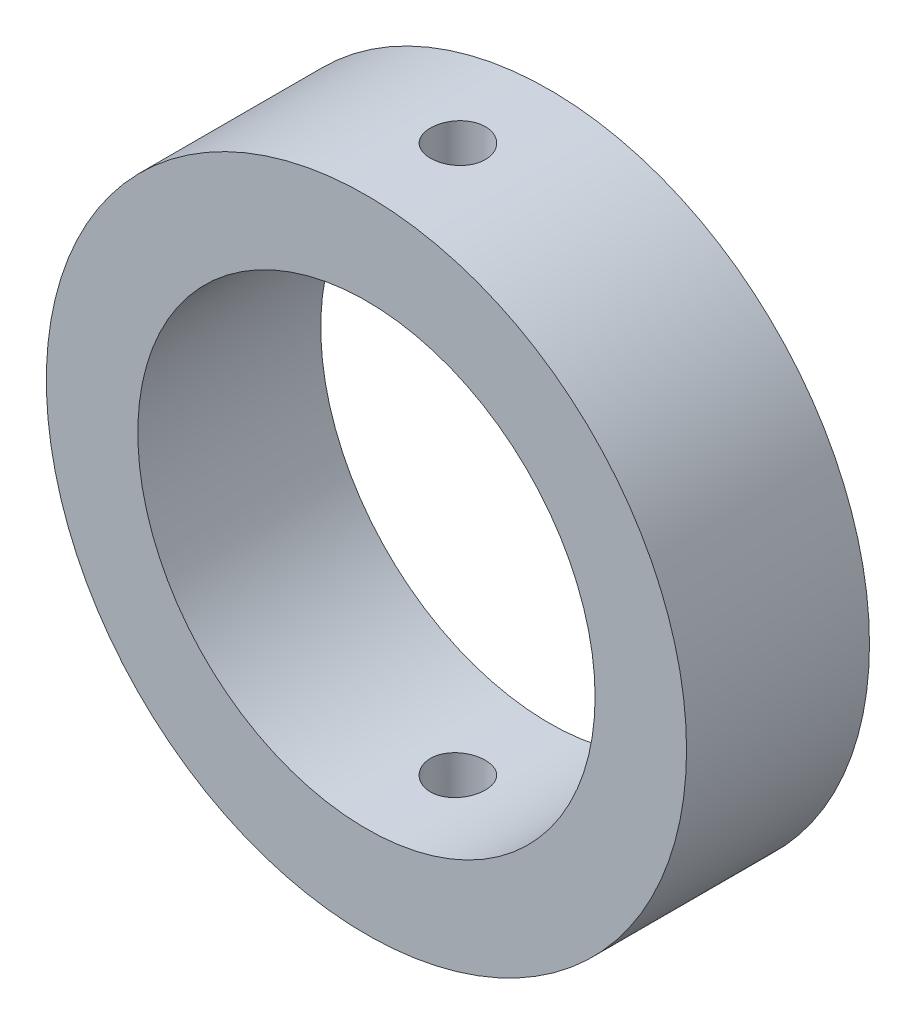
from build123d import *

# Parameters (mm, degrees)
SKETCH1_R               = 350
SKETCH1_R_2             = 250
BOSS_EXTRUDE1_DEPTH     = 200
SKETCH2_R               = 30
CUT_EXTRUDE1_DEPTH      = 351
CUT_EXTRUDE1_DEPTH_BACK = 351


with BuildPart() as part:
    # Sketch1 → Boss-Extrude1 (new body)
    with BuildSketch(Plane.XY):
        Circle(SKETCH1_R)
        Circle(SKETCH1_R_2, mode=Mode.SUBTRACT)
    extrude(amount=BOSS_EXTRUDE1_DEPTH)

    # Sketch2 → Cut-Extrude1 (cut, two sides)
    with BuildSketch(Plane(origin=(0, 0, 0), x_dir=(1, 0, 0), z_dir=(0, 1, 0))) as cut_extrude1_sk:
        with Locations((0, -100)):
            Circle(SKETCH2_R)
    extrude(amount=CUT_EXTRUDE1_DEPTH, mode=Mode.SUBTRACT)
    extrude(cut_extrude1_sk.sketch, amount=-CUT_EXTRUDE1_DEPTH_BACK, mode=Mode.SUBTRACT)


solid = part.part
